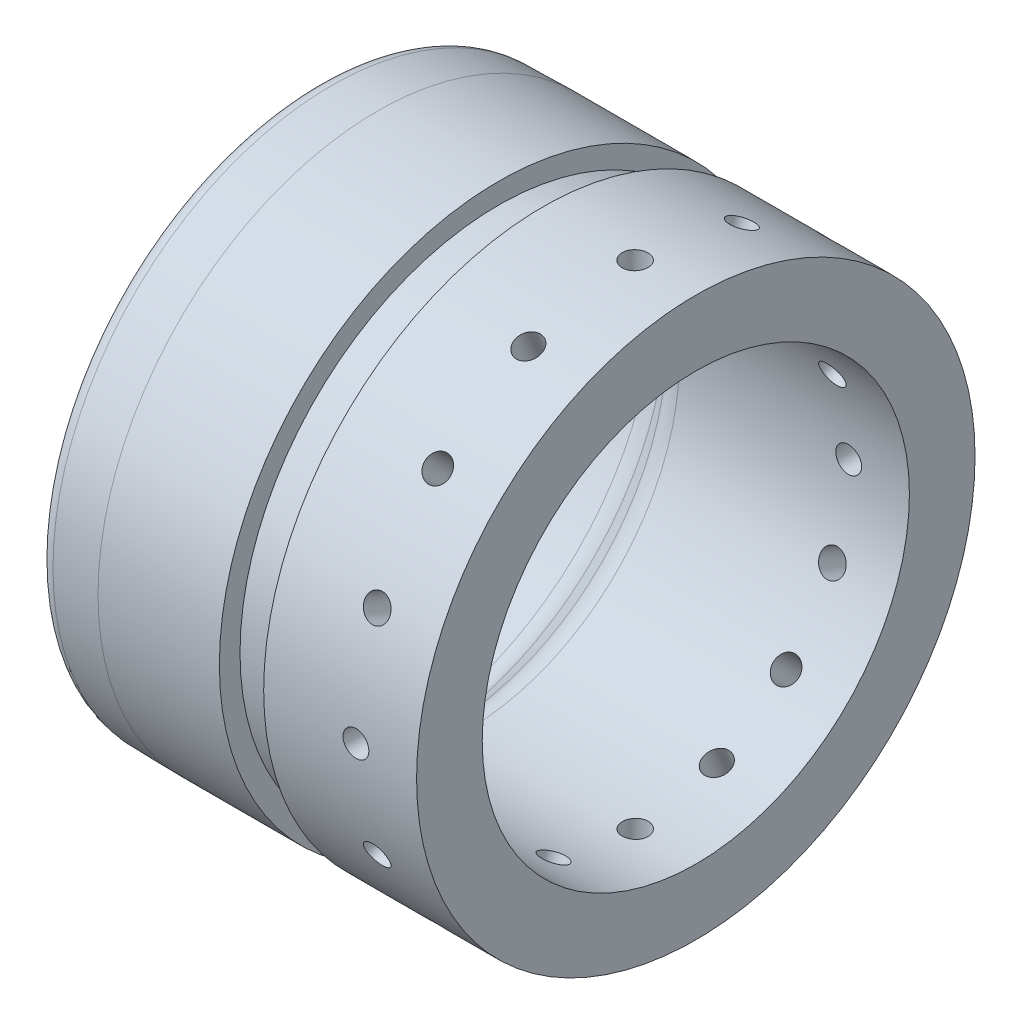
from build123d import *

# Parameters (mm, degrees)
TAP_DRILL_FOR_1_4_28_TAP1_D = 5.4102
TAP_PATTERN_COUNT           = 16
FILLET1_R                   = 3.175


with BuildPart() as part:
    # Sketch1 → Revolve1 (revolve)
    with BuildSketch(Plane.XY):
        with BuildLine():
            Line((1.833826289, 12.382703051), (-3.971429832, 6.57744693))
            ThreePointArc((-3.971429832, 6.57744693), (-6.031518097, 5.200939959), (-8.461557893, 4.717574991))
            Line((-8.461557893, 4.717574991), (-24.899937811, 4.717574991))
            Line((-24.899937811, 4.717574991), (-24.899937811, 0.723179609))
            Line((-24.899937811, 0.723179609), (-12.181301772, 0.501174991))
            Line((-12.181301772, 0.501174991), (13.218698228, 0.501174991))
            Line((13.218698228, 0.501174991), (13.218698228, 4.819174991))
            Line((13.218698228, 4.819174991), (22.489698228, 4.819174991))
            Line((22.489698228, 4.819174991), (22.489698228, 0.501174991))
            Line((22.489698228, 0.501174991), (54.493698228, 0.501174991))
            Line((54.493698228, 0.501174991), (54.493698228, 14.242574991))
            Line((54.493698228, 14.242574991), (6.323954349, 14.242574991))
            ThreePointArc((6.323954349, 14.242574991), (3.893914554, 13.759210022), (1.833826289, 12.382703051))
        make_face()
    revolve(axis=Axis((0.018636039, 58.946574991, 0), (1, 0, 0)))

    # Tap Drill for 1/4-28 Tap1 (through all)
    with Locations(Plane(origin=(0, 0, -58.4454), x_dir=(-1, 0, 0), z_dir=(0, 0, -1))):
        with Locations((-41.793698228, 58.946574991)):
            tap_drill_for_1_4_28_tap1 = Hole(TAP_DRILL_FOR_1_4_28_TAP1_D / 2)

    # Tap Pattern: Tap Drill for 1/4-28 Tap1 ×16 about axis
    tap_pattern_axis = Axis((0.018636039, 58.946574991, 0), (1, 0, 0))
    for i in range(1, TAP_PATTERN_COUNT):
        add(tap_drill_for_1_4_28_tap1.rotate(tap_pattern_axis, i * 360 / TAP_PATTERN_COUNT), mode=Mode.SUBTRACT)

    # Fillet1
    fillet1_edges = [part.edges().sort_by_distance(p)[0] for p in [
        (-24.899937811, 117.169970373, 0),
    ]]
    fillet(fillet1_edges, radius=FILLET1_R)


solid = part.part
